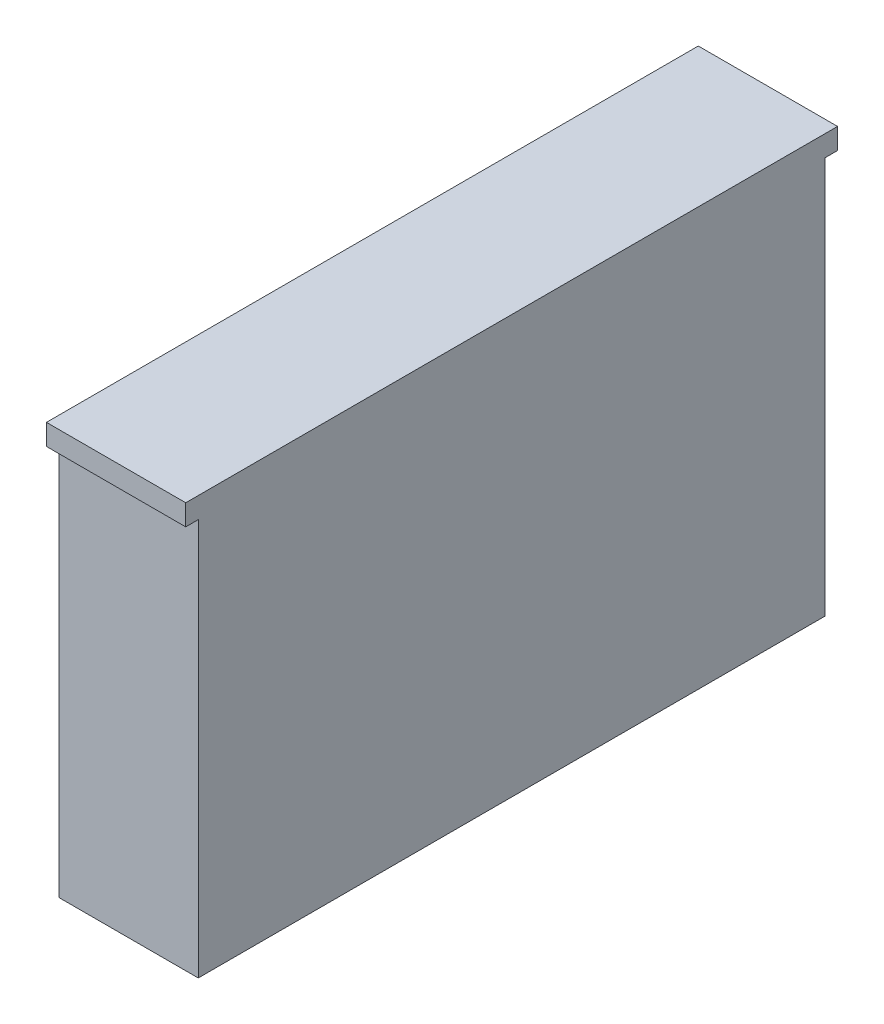
from build123d import *

# Parameters (mm, degrees)
CROQUIS2_W              = 450
CROQUIS2_H              = 300
SALIENTE_EXTRUIR1_DEPTH = 100
CROQUIS4_W              = 100
CROQUIS4_H              = 15
SALIENTE_EXTRUIR2_DEPTH = 9
CROQUIS5_W              = 100
CROQUIS5_H              = 15
SALIENTE_EXTRUIR3_DEPTH = 9


with BuildPart() as part:
    # Croquis2 → Saliente-Extruir1 (new body)
    with BuildSketch(Plane(origin=(0, 0, 0), x_dir=(0, 0, -1), z_dir=(1, 0, 0))):
        Rectangle(CROQUIS2_W, CROQUIS2_H)
    extrude(amount=SALIENTE_EXTRUIR1_DEPTH)

    # Croquis4 → Saliente-Extruir2 (add)
    with BuildSketch(Plane(origin=(0, 0, -225), x_dir=(-1, 0, 0), z_dir=(0, 0, -1))):
        with Locations((-50, 142.5)):
            Rectangle(CROQUIS4_W, CROQUIS4_H)
    extrude(amount=SALIENTE_EXTRUIR2_DEPTH)

    # Croquis5 → Saliente-Extruir3 (add)
    with BuildSketch(Plane.XY.offset(225)):
        with Locations((50, 142.5)):
            Rectangle(CROQUIS5_W, CROQUIS5_H)
    extrude(amount=SALIENTE_EXTRUIR3_DEPTH)


solid = part.part
